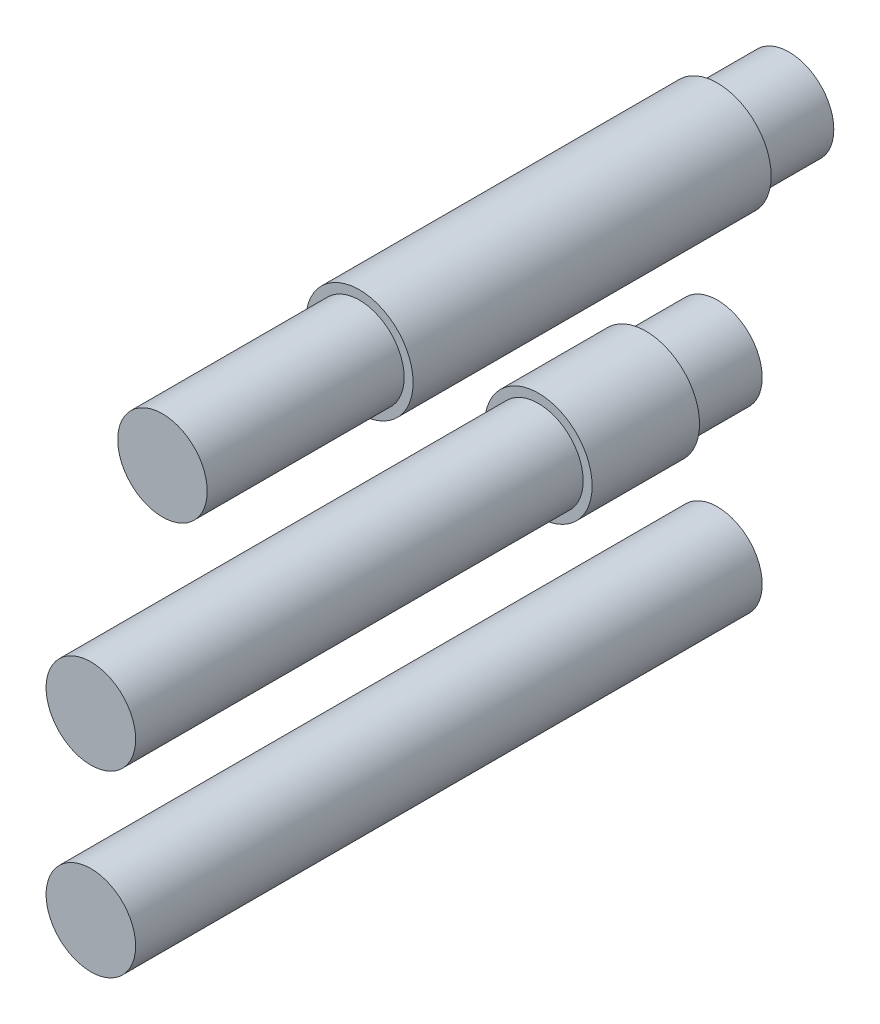
from build123d import *

# Parameters (mm, degrees)
RESSALTO_EXTRUS_O1_DEPTH      = 5.5
RESSALTO_EXTRUS_O1_DEPTH_BACK = 12
ESBO_O1_R                     = 1.25
RESSALTO_EXTRUS_O2_DEPTH      = 12.5
RESSALTO_EXTRUS_O2_DEPTH_BACK = 5
ESBO_O1_4_R                   = 1.25
ESBO_O2_R                     = 1.25
RESSALTO_EXTRUS_O3_DEPTH      = 17.5
ESBO_O6_R                     = 1.5
RESSALTO_EXTRUS_O4_DEPTH      = 10
ESBO_O7_R                     = 1.5
RESSALTO_EXTRUS_O5_DEPTH      = 3


with BuildPart() as part:
    # Esboço1 → Ressalto-extrusão1 (new, two sides: drawn at the far end of the back side and taken through both)
    with BuildSketch(Plane.XY.offset(-RESSALTO_EXTRUS_O1_DEPTH_BACK)):
        with Locations((-5.75452307, 0.792466101)):
            Circle(ESBO_O1_R)
    extrude(amount=RESSALTO_EXTRUS_O1_DEPTH + RESSALTO_EXTRUS_O1_DEPTH_BACK)

    # Esboço6 → Ressalto-extrusão4 (add)
    with BuildSketch(Plane.XY):
        with Locations((-5.75452307, 0.792466101)):
            Circle(ESBO_O6_R)
    extrude(amount=-RESSALTO_EXTRUS_O4_DEPTH)


with BuildPart() as body_2:
    # Esboço1<4> → Ressalto-extrusão2 (new, two sides: drawn at the far end of the back side and taken through both)
    with BuildSketch(Plane.XY.offset(-RESSALTO_EXTRUS_O2_DEPTH_BACK)):
        with Locations((-0.75452307, 0.792466101)):
            Circle(ESBO_O1_4_R)
    extrude(amount=RESSALTO_EXTRUS_O2_DEPTH + RESSALTO_EXTRUS_O2_DEPTH_BACK)


with BuildPart() as body_3:
    # Esboço2 → Ressalto-extrusão3 (new body)
    with BuildSketch(Plane.XY):
        with Locations((4.24547693, 0.792466101)):
            Circle(ESBO_O2_R)
    extrude(amount=RESSALTO_EXTRUS_O3_DEPTH)


with BuildPart() as body_4:
    # Esboço7 → Ressalto-extrusão5 (new body)
    with BuildSketch(Plane.XY):
        with Locations((-0.75452307, 0.792466101)):
            Circle(ESBO_O7_R)
    extrude(amount=-RESSALTO_EXTRUS_O5_DEPTH)


solid = Compound([part.part, body_2.part, body_3.part, body_4.part])
